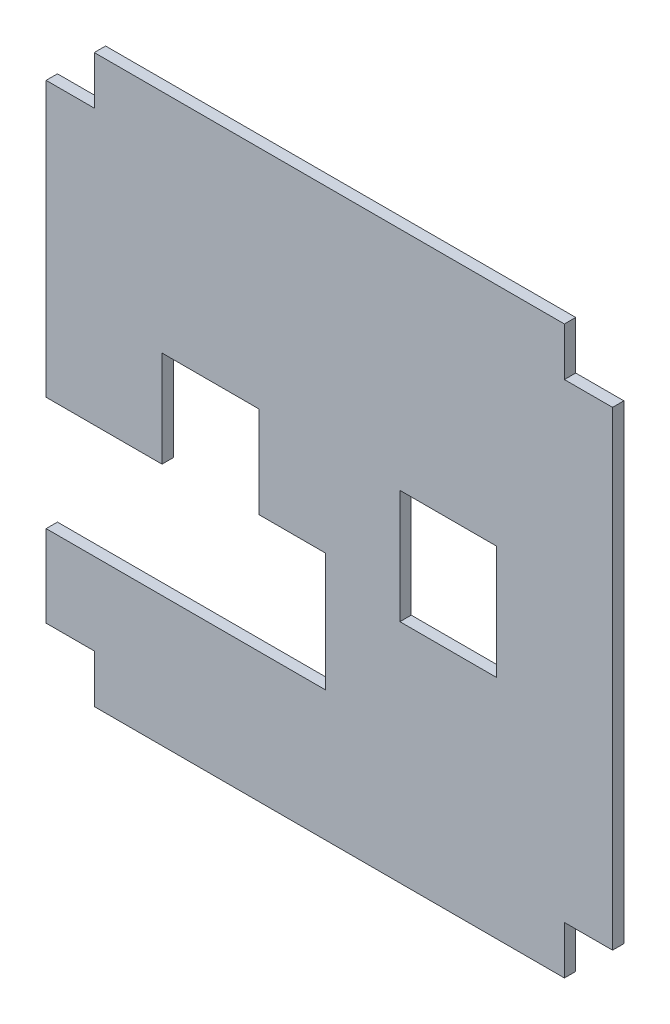
from build123d import *

# Parameters (mm, degrees)
SKETCH1_W           = 17.080006479
SKETCH1_H           = 20.0800081
BOSS_EXTRUDE1_DEPTH = 2


with BuildPart() as part:
    # Sketch1 → Boss-Extrude1 (new body)
    with BuildSketch(Plane.XY):
        Polygon((-158.225691519, -298.776294453), (-158.225691519, -313.236290403), (-149.725691519, -313.236290403), (-149.725691519, -321.736290403), (-66.725691519, -321.736290403), (-66.725691519, -313.236290403), (-58.225691519, -313.236290403), (-58.225691519, -230.236290403), (-66.725691519, -230.236290403), (-66.725691519, -221.736290403), (-149.725691519, -221.736290403), (-149.725691519, -230.236290403), (-158.225691519, -230.236290403), (-158.225691519, -278.696286353), (-137.765694759, -278.696286353), (-137.765694759, -261.696286353), (-120.68568828, -261.696286353), (-120.68568828, -277.85605527), (-108.863916488, -277.85605527), (-108.863916488, -281.776294453), (-108.863916488, -298.776294453), (-122.185689089, -298.776294453), align=None)
        with Locations((-87.225691519, -271.736290403)):
            Rectangle(SKETCH1_W, SKETCH1_H, mode=Mode.SUBTRACT)
    extrude(amount=BOSS_EXTRUDE1_DEPTH)


solid = part.part
